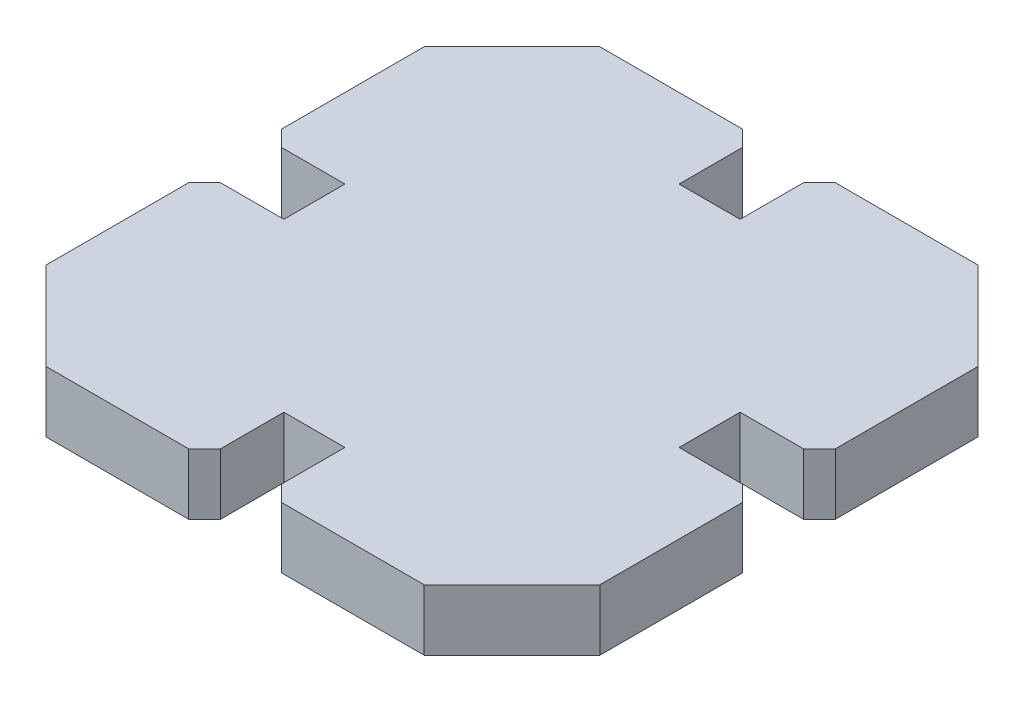
from build123d import *

# Parameters (mm, degrees)
BOSS_EXTRUDE1_DEPTH = 3.85
CHAMFER1_SIZE       = 1


with BuildPart() as part:
    # Sketch1 → Boss-Extrude1 (new body)
    with BuildSketch(Plane(origin=(0, 0, 0), x_dir=(1, 0, 0), z_dir=(0, 1, 0))):
        Polygon((17.46076087, -11.925), (11.925, -17.46076087), (1.925, -17.46076087), (1.925, -12.46076087), (-1.925, -12.46076087), (-1.925, -17.46076087), (-11.925, -17.46076087), (-17.46076087, -11.925), (-17.46076087, -1.925), (-12.46076087, -1.925), (-12.46076087, 1.925), (-17.46076087, 1.925), (-17.46076087, 11.925), (-11.925, 17.46076087), (-1.925, 17.46076087), (-1.925, 12.46076087), (1.925, 12.46076087), (1.925, 17.46076087), (11.925, 17.46076087), (17.46076087, 11.925), (17.46076087, 1.925), (12.46076087, 1.925), (12.46076087, -1.925), (17.46076087, -1.925), align=None)
    extrude(amount=BOSS_EXTRUDE1_DEPTH)

    # Chamfer1
    chamfer1_edges = [part.edges().sort_by_distance(p)[0] for p in [
        (17.46076087, 1.925, -1.925),
        (17.46076087, 1.925, 1.925),
        (1.925, 1.925, 17.46076087),
        (-1.925, 1.925, 17.46076087),
        (-17.46076087, 1.925, 1.925),
        (-17.46076087, 1.925, -1.925),
        (-1.925, 1.925, -17.46076087),
        (1.925, 1.925, -17.46076087),
    ]]
    chamfer(chamfer1_edges, length=CHAMFER1_SIZE)


solid = part.part
